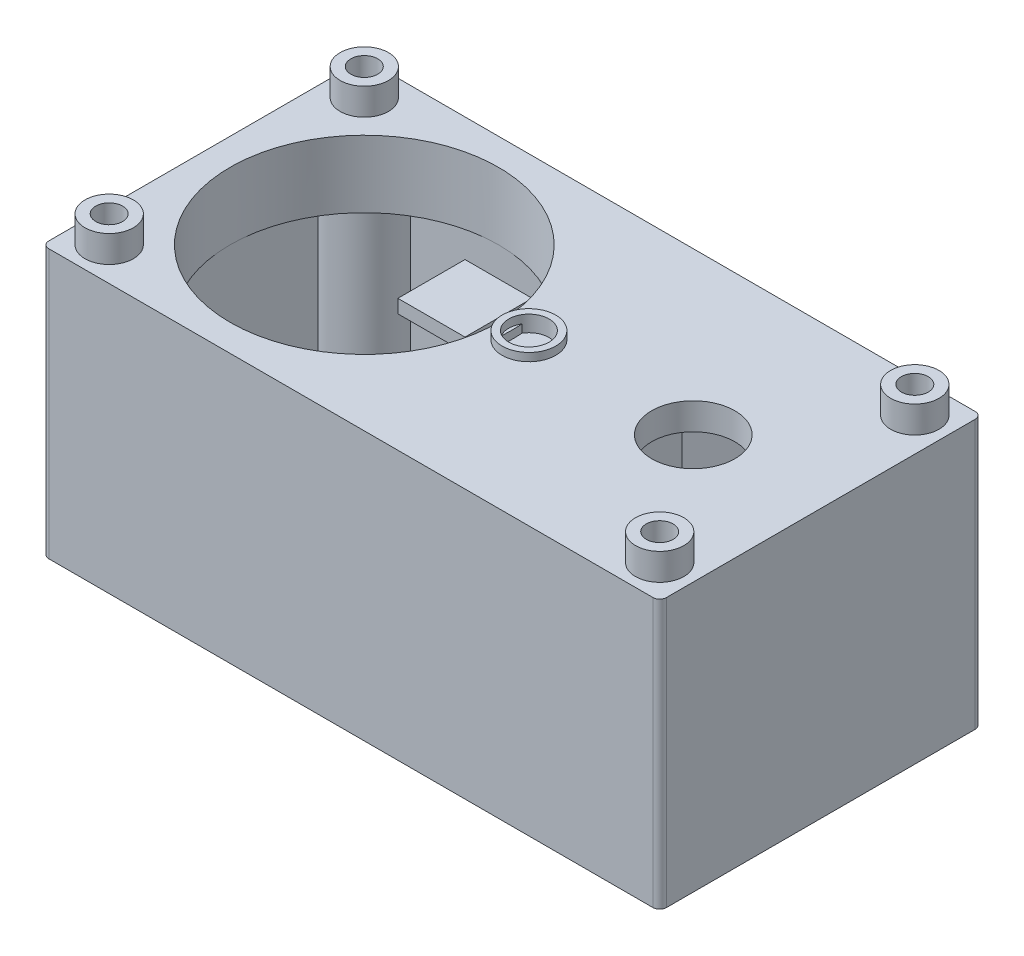
from build123d import *

# Parameters (mm, degrees)
SKETCH1_W           = 23
SKETCH1_H           = 12
SKETCH1_R           = 0.5
BOSS_EXTRUDE1_DEPTH = 10
SHELL1_T            = -1
EXTRUDE_THIN1_START = 10
SKETCH1_3_R         = 0.9
SKETCH1_3_R_2       = 0.5
EXTRUDE_THIN1_DEPTH = 1
CUT_EXTRUDE1_REACH  = 18.378
SKETCH2_R           = 5
SKETCH2_R_2         = 1.55
SKETCH2_3_R         = 1
SKETCH2_3_R_2       = 0.75
EXTRUDE_THIN2_DEPTH = 0.3
CUT_EXTRUDE2_START  = -0.3
SKETCH5_R           = 0.75
CUT_EXTRUDE2_DEPTH  = 0.3
EXTRUDE_THIN3_DEPTH = 5
SKETCH2_5_R         = 5.5
SKETCH2_5_R_2       = 5
EXTRUDE_THIN4_DEPTH = 2.5
BOSS_EXTRUDE2_START = -3.6
SKETCH7_W           = 2.5
SKETCH7_H           = 2.5
BOSS_EXTRUDE2_DEPTH = 0.5
FILLET1_R           = 0.25


with BuildPart() as part:
    # Sketch1 → Boss-Extrude1 (new body)
    with BuildSketch(Plane(origin=(0, 0, 0), x_dir=(1, 0, 0), z_dir=(0, 1, 0))):
        Rectangle(SKETCH1_W, SKETCH1_H)
        with Locations((-10.25, 4.75)):
            Circle(SKETCH1_R, mode=Mode.SUBTRACT)
        with Locations((-10.25, -4.75)):
            Circle(SKETCH1_R, mode=Mode.SUBTRACT)
        with Locations((10.25, -4.75)):
            Circle(SKETCH1_R, mode=Mode.SUBTRACT)
        with Locations((10.25, 4.75)):
            Circle(SKETCH1_R, mode=Mode.SUBTRACT)
    extrude(amount=BOSS_EXTRUDE1_DEPTH)

    # Shell1
    shell1_openings = [part.faces().sort_by_distance(p)[0] for p in [
        (0, 0, 0),
    ]]
    offset(amount=SHELL1_T, openings=shell1_openings)

    # Sketch1_3 → Extrude-Thin1 (add)
    # profile 1 of 4: a face of its own
    with BuildSketch(Plane(origin=(0, 0, 0), x_dir=(1, 0, 0), z_dir=(0, 1, 0)).offset(EXTRUDE_THIN1_START)):
        with Locations((-10.25, 4.75)):
            Circle(SKETCH1_3_R)
        with Locations((-10.25, 4.75)):
            Circle(SKETCH1_3_R_2, mode=Mode.SUBTRACT)
    # profile 2 of 4: a face of its own
    with BuildSketch(Plane(origin=(0, 0, 0), x_dir=(1, 0, 0), z_dir=(0, 1, 0)).offset(EXTRUDE_THIN1_START)):
        with Locations((-10.25, -4.75)):
            Circle(SKETCH1_3_R)
        with Locations((-10.25, -4.75)):
            Circle(SKETCH1_3_R_2, mode=Mode.SUBTRACT)
    # profile 3 of 4: a face of its own
    with BuildSketch(Plane(origin=(0, 0, 0), x_dir=(1, 0, 0), z_dir=(0, 1, 0)).offset(EXTRUDE_THIN1_START)):
        with Locations((10.25, -4.75)):
            Circle(SKETCH1_3_R)
        with Locations((10.25, -4.75)):
            Circle(SKETCH1_3_R_2, mode=Mode.SUBTRACT)
    # profile 4 of 4: a face of its own
    with BuildSketch(Plane(origin=(0, 0, 0), x_dir=(1, 0, 0), z_dir=(0, 1, 0)).offset(EXTRUDE_THIN1_START)):
        with Locations((10.25, 4.75)):
            Circle(SKETCH1_3_R)
        with Locations((10.25, 4.75)):
            Circle(SKETCH1_3_R_2, mode=Mode.SUBTRACT)
    extrude(amount=EXTRUDE_THIN1_DEPTH)

    # Sketch2 → Cut-Extrude1 (cut, up to next)
    with BuildSketch(Plane(origin=(0, 10, 0), x_dir=(1, 0, 0), z_dir=(0, 1, 0)), mode=Mode.PRIVATE) as cut_extrude1_sk1:
        with Locations((-5.5, 0)):
            Circle(SKETCH2_R)
    cut_extrude1_tool1 = extrude(cut_extrude1_sk1.sketch, amount=-CUT_EXTRUDE1_REACH, mode=Mode.PRIVATE) & part.part
    # Sketch2 → Cut-Extrude1 (cut, up to next)
    with BuildSketch(Plane(origin=(0, 10, 0), x_dir=(1, 0, 0), z_dir=(0, 1, 0)), mode=Mode.PRIVATE) as cut_extrude1_sk2:
        with Locations((6.75, 0)):
            Circle(SKETCH2_R_2)
    cut_extrude1_tool2 = extrude(cut_extrude1_sk2.sketch, amount=-CUT_EXTRUDE1_REACH, mode=Mode.PRIVATE) & part.part
    add(cut_extrude1_tool1.solids().sort_by_distance((-5.5, 10, 0))[0], mode=Mode.SUBTRACT)
    add(cut_extrude1_tool2.solids().sort_by_distance((6.75, 10, 0))[0], mode=Mode.SUBTRACT)

    # Sketch2_3 → Extrude-Thin2 (add)
    with BuildSketch(Plane(origin=(0, 10, 0), x_dir=(1, 0, 0), z_dir=(0, 1, 0))):
        with Locations((0.63, 0)):
            Circle(SKETCH2_3_R)
        with Locations((0.63, 0)):
            Circle(SKETCH2_3_R_2, mode=Mode.SUBTRACT)
    extrude(amount=EXTRUDE_THIN2_DEPTH)

    # Sketch5 → Cut-Extrude2 (cut)
    with BuildSketch(Plane(origin=(0, 10, 0), x_dir=(1, 0, 0), z_dir=(0, 1, 0)).offset(CUT_EXTRUDE2_START)):
        with Locations((0.63, 0)):
            Circle(SKETCH5_R)
    extrude(amount=CUT_EXTRUDE2_DEPTH, mode=Mode.SUBTRACT)

    # Sketch6 → Extrude-Thin3 (add)
    with BuildSketch(Plane.XZ.offset(-9)):
        Polygon((4.575, 5), (2.95, 3.375), (2.95, -3.375), (4.575, -5), (4.221446609, -5.353553391), (2.45, -3.582106781), (2.45, 3.582106781), (4.221446609, 5.353553391), align=None)
    extrude(amount=EXTRUDE_THIN3_DEPTH)

    # Sketch2_5 → Extrude-Thin4 (add)
    with BuildSketch(Plane(origin=(0, 10, 0), x_dir=(1, 0, 0), z_dir=(0, 1, 0))):
        with Locations((-5.5, 0)):
            Circle(SKETCH2_5_R)
        with Locations((-5.5, 0)):
            Circle(SKETCH2_5_R_2, mode=Mode.SUBTRACT)
    extrude(amount=-EXTRUDE_THIN4_DEPTH)

    # Sketch7 → Boss-Extrude2 (add)
    with BuildSketch(Plane(origin=(0, 10, 0), x_dir=(1, 0, 0), z_dir=(0, 1, 0)).offset(BOSS_EXTRUDE2_START)):
        with Locations((-5.5, 3.75)):
            Rectangle(SKETCH7_W, SKETCH7_H)
        with Locations((-5.5, -3.75)):
            Rectangle(SKETCH7_W, SKETCH7_H)
    extrude(amount=-BOSS_EXTRUDE2_DEPTH)

    # Fillet1
    fillet1_edges = [part.edges().sort_by_distance(p)[0] for p in [
        (11.5, 5, 6),
        (11.5, 5, -6),
        (-11.5, 5, -6),
        (-11.5, 5, 6),
    ]]
    fillet(fillet1_edges, radius=FILLET1_R)


solid = part.part
